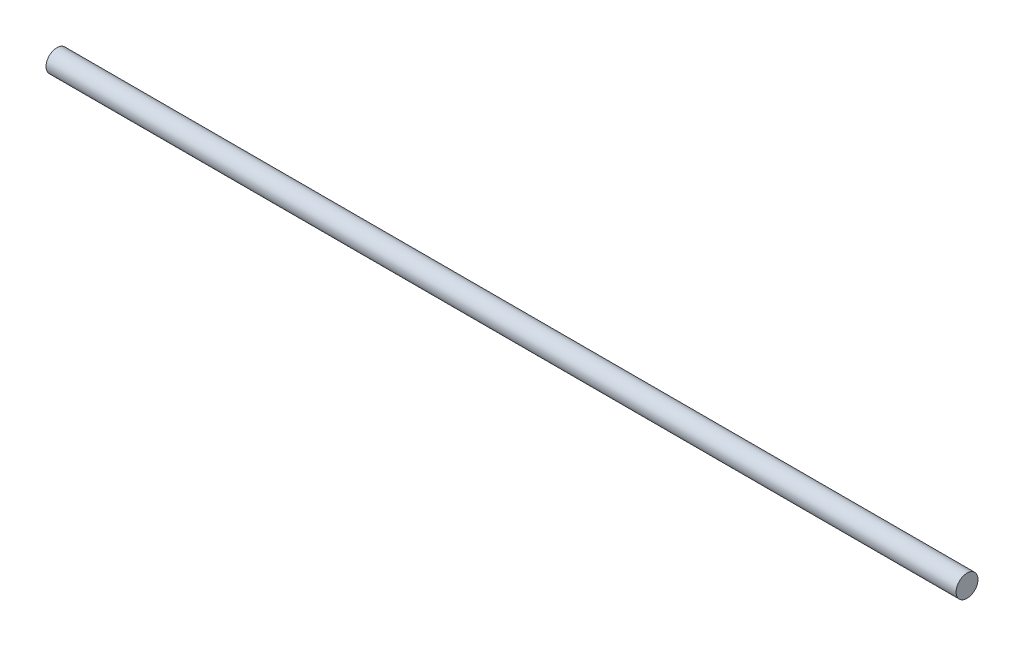
from build123d import *


with BuildPart() as part:
    # Sketch1 → Revolve2 (revolve)
    with BuildSketch(Plane.XY):
        Polygon((-124.5, 0), (124.5, 0), (124.5, 3), (0, 3), (-124.5, 3), align=None)
    revolve(axis=Axis((-124.5, 0, 0), (1, 0, 0)))


solid = part.part
